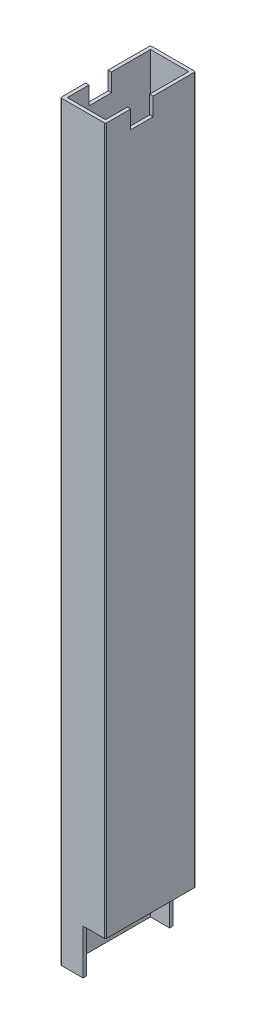
from build123d import *

# Parameters (mm, degrees)
SKETCH1_W           = 17
SKETCH1_H           = 37
BOSS_EXTRUDE1_DEPTH = 334
SKETCH2_W           = 10
SKETCH2_H           = 20
CUT_EXTRUDE1_DEPTH  = 40
SKETCH4_W           = 10
SKETCH4_H           = 8
CUT_EXTRUDE3_DEPTH  = 337.980711614


with BuildPart() as part:
    # Sketch1 → Boss-Extrude1 (new body)
    with BuildSketch(Plane(origin=(0, 0, 0), x_dir=(1, 0, 0), z_dir=(0, 1, 0))):
        with BuildLine():
            Line((0.5, 0), (19.5, 0))
            ThreePointArc((19.5, 0), (19.853553391, 0.146446609), (20, 0.5))
            Line((20, 0.5), (20, 39.5))
            ThreePointArc((20, 39.5), (19.853553391, 39.853553391), (19.5, 40))
            Line((19.5, 40), (0.5, 40))
            ThreePointArc((0.5, 40), (0.146446609, 39.853553391), (0, 39.5))
            Line((0, 39.5), (0, 0.5))
            ThreePointArc((0, 0.5), (0.146446609, 0.146446609), (0.5, 0))
        make_face()
        with Locations((10, 20)):
            Rectangle(SKETCH1_W, SKETCH1_H, mode=Mode.SUBTRACT)
    extrude(amount=BOSS_EXTRUDE1_DEPTH)

    # Sketch2 → Cut-Extrude1 (cut)
    with BuildSketch(Plane.XY):
        with Locations((15, 10)):
            Rectangle(SKETCH2_W, SKETCH2_H)
    extrude(amount=-CUT_EXTRUDE1_DEPTH, mode=Mode.SUBTRACT)

    # Sketch4 → Cut-Extrude3 (cut, through all)
    with BuildSketch(Plane(origin=(20, 0, 0), x_dir=(0, 0, -1), z_dir=(1, 0, 0))):
        with Locations((16.16, 330)):
            Rectangle(SKETCH4_W, SKETCH4_H)
    extrude(amount=-CUT_EXTRUDE3_DEPTH, mode=Mode.SUBTRACT)


solid = part.part
